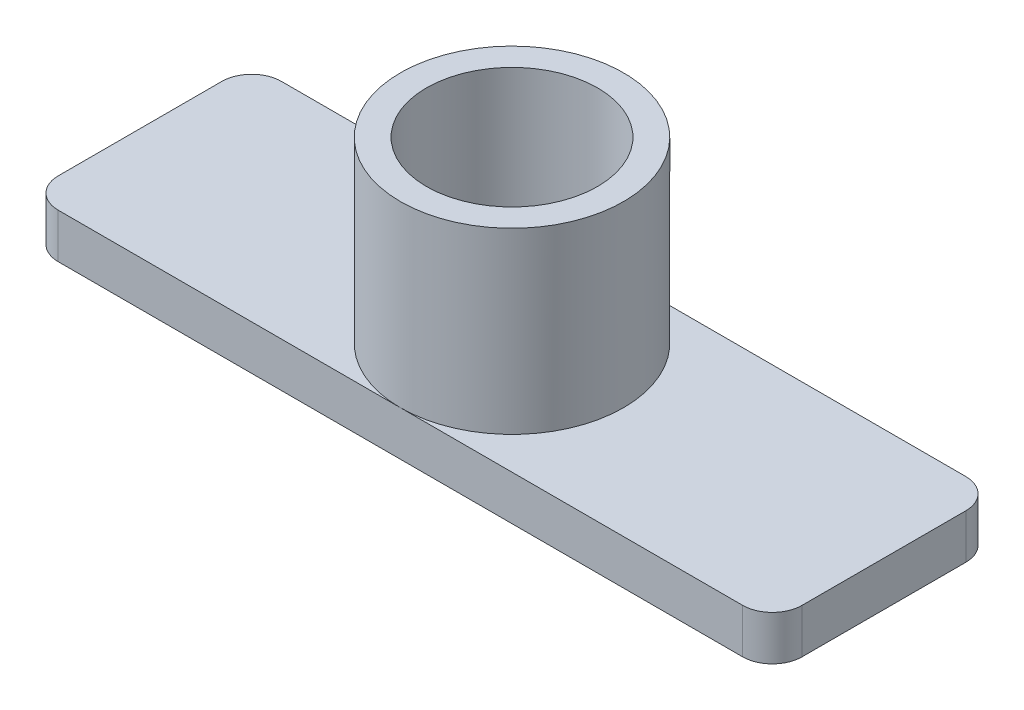
from build123d import *

# Parameters (mm, degrees)
SKIZZE1_W                       = 50
SKIZZE1_H                       = 15
AUFSATZ_LINEAR_AUSTRAGEN1_DEPTH = 3
SKIZZE2_R                       = 7.5
SKIZZE2_R_2                     = 5.75
AUFSATZ_LINEAR_AUSTRAGEN2_DEPTH = 12
VERRUNDUNG1_R                   = 2


with BuildPart() as part:
    # Skizze1 → Aufsatz-Linear austragen1 (new body)
    with BuildSketch(Plane(origin=(0, 0, 0), x_dir=(1, 0, 0), z_dir=(0, 1, 0))):
        Rectangle(SKIZZE1_W, SKIZZE1_H)
    extrude(amount=AUFSATZ_LINEAR_AUSTRAGEN1_DEPTH)

    # Skizze2 → Aufsatz-Linear austragen2 (add)
    with BuildSketch(Plane(origin=(0, 3, 0), x_dir=(1, 0, 0), z_dir=(0, 1, 0))):
        Circle(SKIZZE2_R)
        Circle(SKIZZE2_R_2, mode=Mode.SUBTRACT)
    extrude(amount=AUFSATZ_LINEAR_AUSTRAGEN2_DEPTH)

    # Verrundung1
    verrundung1_edges = [part.edges().sort_by_distance(p)[0] for p in [
        (25, 1.5, 7.5),
        (-25, 1.5, 7.5),
        (-25, 1.5, -7.5),
        (25, 1.5, -7.5),
    ]]
    fillet(verrundung1_edges, radius=VERRUNDUNG1_R)


solid = part.part
